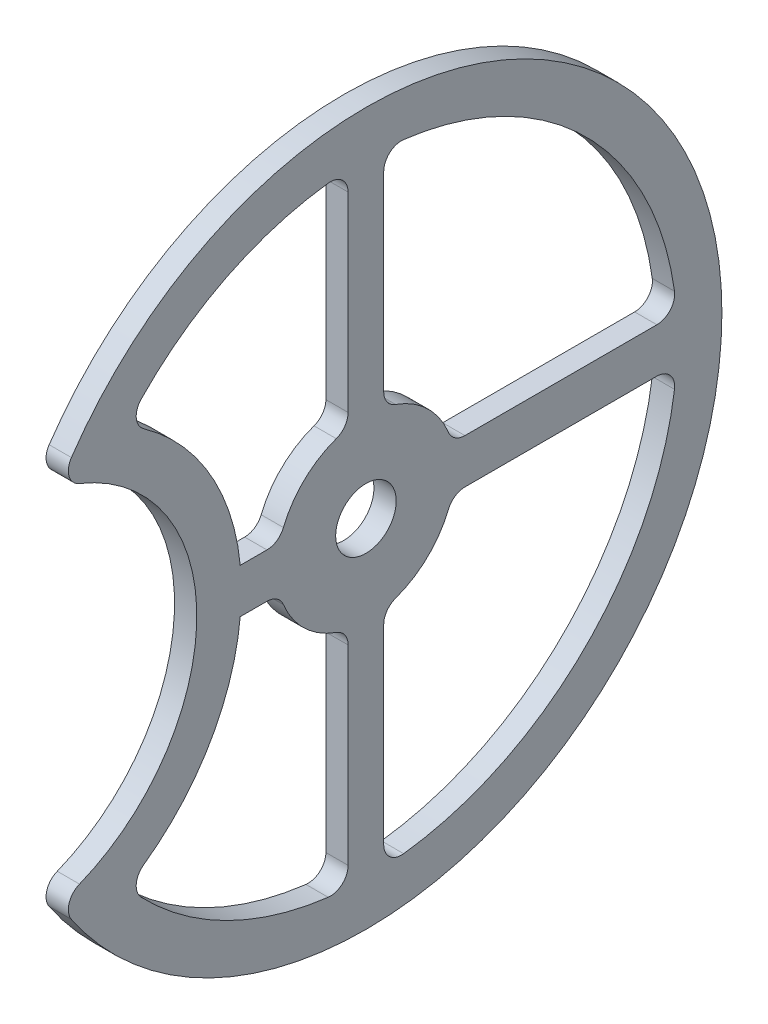
from build123d import *

# Parameters (mm, degrees)
SKETCH1_R           = 1.6
BOSS_EXTRUDE1_DEPTH = 2.5
FILLET1_R           = 2
SKETCH2_R           = 3.4
CUT_EXTRUDE1_DEPTH  = 3.5000001


with BuildPart() as part:
    # Sketch1 → Boss-Extrude1 (new body)
    with BuildSketch(Plane(origin=(0, 0, 0), x_dir=(0, 0, -1), z_dir=(1, 0, 0))):
        with BuildLine():
            ThreePointArc((-34.4875, 20.263571841), (-19, 0), (-34.4875, -20.263571841))
            ThreePointArc((-34.4875, -20.263571841), (40, 0), (-34.4875, 20.263571841))
        make_face()
        with BuildLine():
            Line((-9.682458366, 2.5), (-14.120471411, 2.5))
            ThreePointArc((-14.120471411, 2.5), (-18.092232837, 14.001776242), (-26.8625, 22.436713078))
            ThreePointArc((-26.8625, 22.436713078), (-15.727733284, 31.267209753), (-2, 34.942810419))
            Line((-2, 34.942810419), (-2, 9.797958971))
            ThreePointArc((-2, 9.797958971), (-6.887307867, 7.250171746), (-9.682458366, 2.5))
        make_face(mode=Mode.SUBTRACT)
        with BuildLine():
            Line((-14.120471411, -2.5), (-9.682458366, -2.5))
            ThreePointArc((-9.682458366, -2.5), (-6.887307867, -7.250171746), (-2, -9.797958971))
            Line((-2, -9.797958971), (-2, -34.942810419))
            ThreePointArc((-2, -34.942810419), (-15.727733284, -31.267209753), (-26.8625, -22.436713078))
            ThreePointArc((-26.8625, -22.436713078), (-18.092232837, -14.001776242), (-14.120471411, -2.5))
        make_face(mode=Mode.SUBTRACT)
        with BuildLine():
            ThreePointArc((2, -9.797958971), (6.887307867, -7.250171746), (9.682458366, -2.5))
            Line((9.682458366, -2.5), (34.910600109, -2.5))
            ThreePointArc((34.910600109, -2.5), (24.570960239, -24.925246497), (2, -34.942810419))
            Line((2, -34.942810419), (2, -9.797958971))
        make_face(mode=Mode.SUBTRACT)
        with BuildLine():
            Line((34.910600109, 2.5), (9.682458366, 2.5))
            ThreePointArc((9.682458366, 2.5), (6.887307867, 7.250171746), (2, 9.797958971))
            Line((2, 9.797958971), (2, 34.942810419))
            ThreePointArc((2, 34.942810419), (24.570960239, 24.925246497), (34.910600109, 2.5))
        make_face(mode=Mode.SUBTRACT)
        Circle(SKETCH1_R, mode=Mode.SUBTRACT)
    extrude(amount=BOSS_EXTRUDE1_DEPTH)

    # Fillet1
    fillet1_edges = [part.edges().sort_by_distance(p)[0] for p in [
        (1.25, 20.263571841, 34.4875),
        (1.25, -20.263571841, 34.4875),
        (1.25, 9.797958971, 2),
        (1.25, 34.942810419, 2),
        (1.25, 22.436713078, 26.8625),
        (1.25, 2.5, 9.682458366),
        (1.25, 2.5, -34.910600109),
        (1.25, 34.942810419, -2),
        (1.25, 9.797958971, -2),
        (1.25, 2.5, -9.682458366),
        (1.25, -22.436713078, 26.8625),
        (1.25, -34.942810419, 2),
        (1.25, -9.797958971, 2),
        (1.25, -2.5, 9.682458366),
        (1.25, -9.797958971, -2),
        (1.25, -34.942810419, -2),
        (1.25, -2.5, -34.910600109),
        (1.25, -2.5, -9.682458366),
    ]]
    fillet(fillet1_edges, radius=FILLET1_R)

    # Sketch2 → Cut-Extrude1 (cut, through all)
    with BuildSketch(Plane.ZY):
        Circle(SKETCH2_R)
    extrude(amount=-CUT_EXTRUDE1_DEPTH, mode=Mode.SUBTRACT)


solid = part.part
